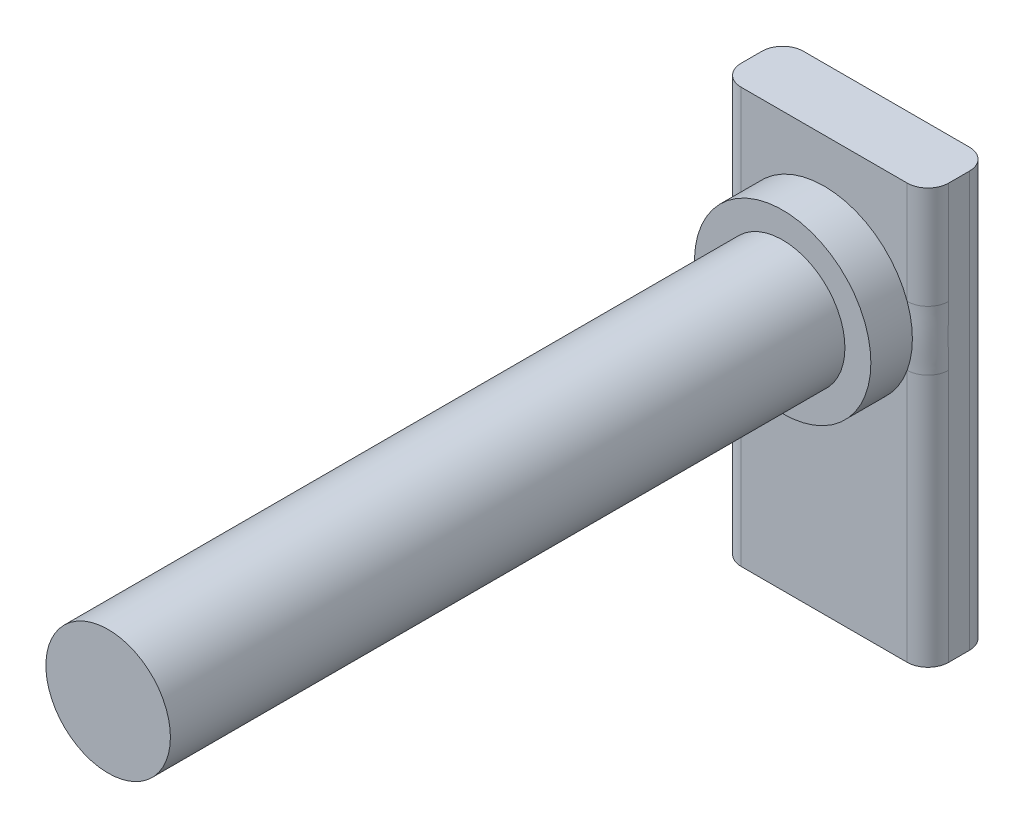
from build123d import *

# Parameters (mm, degrees)
SKETCH1_W           = 20
SKETCH1_H           = 6
BOSS_EXTRUDE1_DEPTH = 40
SKETCH5_R           = 6
BOSS_EXTRUDE8_DEPTH = 69
SKETCH8_R           = 8.5
BOSS_EXTRUDE9_DEPTH = 4
FILLET1_R           = 2


with BuildPart() as part:
    # Sketch1 → Boss-Extrude1 (new body)
    with BuildSketch(Plane(origin=(0, 0, 0), x_dir=(1, 0, 0), z_dir=(0, 1, 0))):
        Rectangle(SKETCH1_W, SKETCH1_H)
    extrude(amount=BOSS_EXTRUDE1_DEPTH)

    # Sketch5 → Boss-Extrude8 (add)
    with BuildSketch(Plane.XY.offset(3)):
        with Locations((0, 27.25)):
            Circle(SKETCH5_R)
    extrude(amount=BOSS_EXTRUDE8_DEPTH)

    # Sketch8 → Boss-Extrude9 (add)
    with BuildSketch(Plane.XY.offset(3)):
        with Locations((0, 27.25)):
            Circle(SKETCH8_R)
    extrude(amount=BOSS_EXTRUDE9_DEPTH)

    # Fillet1
    fillet1_edges = [part.edges().sort_by_distance(p)[0] for p in [
        (-10, 20, -3),
        (10, 20, -3),
        (10, 20, 3),
        (-10, 20, 3),
    ]]
    fillet(fillet1_edges, radius=FILLET1_R)


solid = part.part
